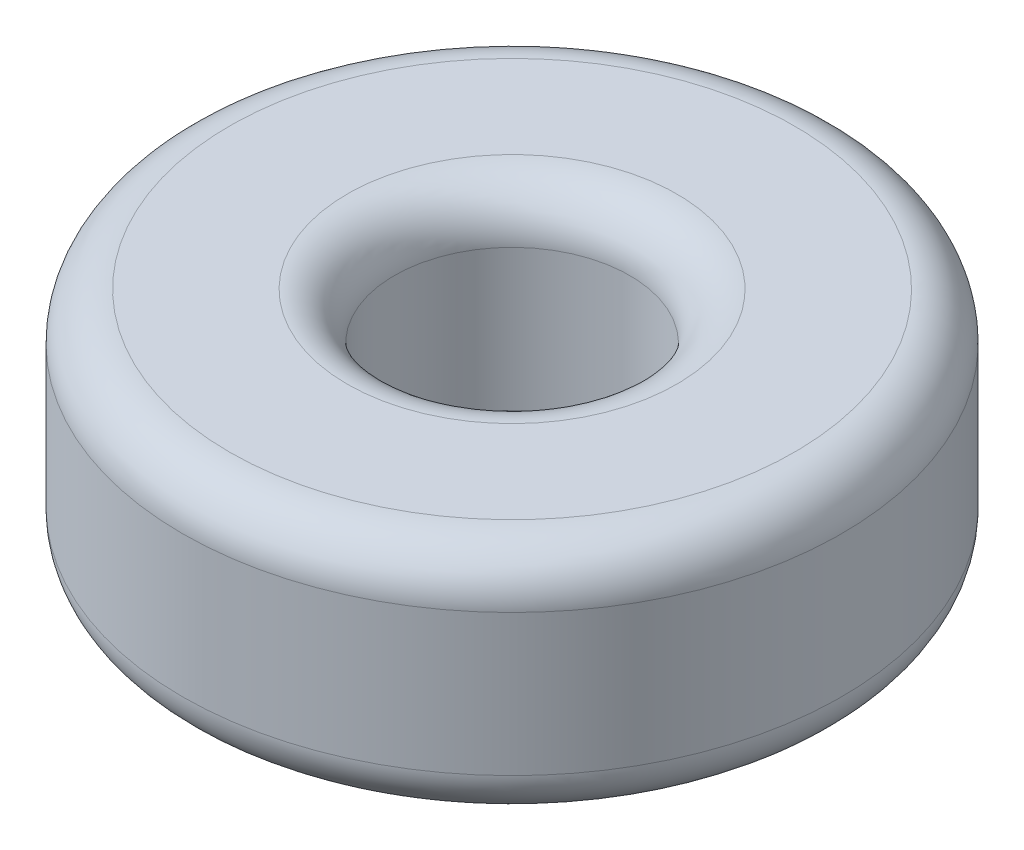
from build123d import *

# Parameters (mm, degrees)
SKETCH1_R           = 7
SKETCH1_R_2         = 2.5
BOSS_EXTRUDE1_DEPTH = 5
FILLET1_R           = 1
FILLET2_R           = 1


with BuildPart() as part:
    # Sketch1 → Boss-Extrude1 (new body)
    with BuildSketch(Plane(origin=(0, 0, 0), x_dir=(1, 0, 0), z_dir=(0, 1, 0))):
        Circle(SKETCH1_R)
        Circle(SKETCH1_R_2, mode=Mode.SUBTRACT)
    extrude(amount=BOSS_EXTRUDE1_DEPTH)

    # Fillet1
    fillet1_edges = [part.edges().sort_by_distance(p)[0] for p in [
        (-7, 0, 0),
        (-7, 5, 0),
    ]]
    fillet(fillet1_edges, radius=FILLET1_R)

    # Fillet2
    fillet2_edges = [part.edges().sort_by_distance(p)[0] for p in [
        (-2.5, 0, 0),
        (-2.5, 5, 0),
    ]]
    fillet(fillet2_edges, radius=FILLET2_R)


solid = part.part
